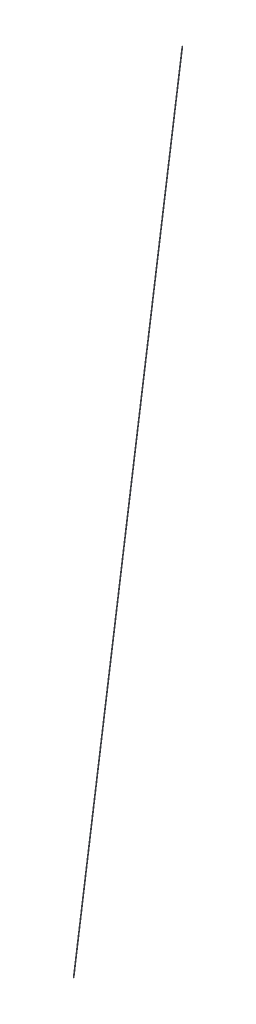
from build123d import *

# Parameters (mm, degrees)
SWEEP_1_PROFILE_R = 0.5


with BuildPart() as part:
    # 扫描1: sweep along a path in 草图3
    with BuildLine(Plane(origin=(0, 0, 0), x_dir=(0, 0, -1), z_dir=(1, 0, 0))) as sweep_1_path:
        Line((0, 1505), (-217.5, 0))
    # 扫描1 profile (on start of the path) → 扫描1 (sweep)
    with BuildSketch(Plane(origin=(0, 1505, 0), x_dir=(0, -0.143032338, -0.989718016), z_dir=(0, -0.989718016, 0.143032338))):
        Circle(SWEEP_1_PROFILE_R)
    sweep(path=sweep_1_path.line)


solid = part.part
